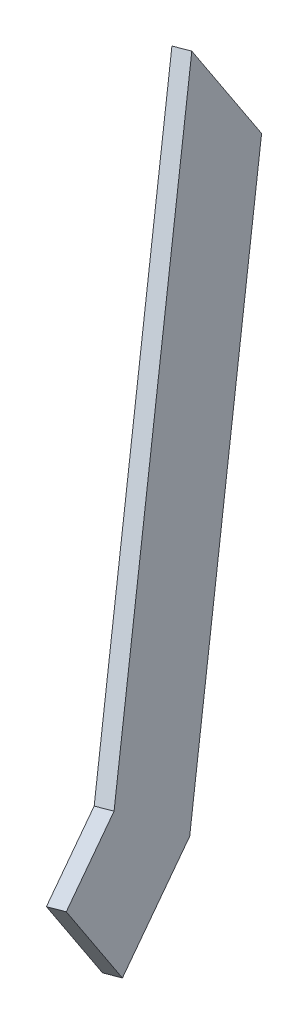
from build123d import *

# Parameters (mm, degrees)
BOSS_EXTRUDE1_DEPTH = 5


with BuildPart() as part:
    # Sketch1 → Boss-Extrude1 (new body)
    with BuildSketch(Plane(origin=(-10.241156446, -1.348234303, 2.051316814), x_dir=(-0.233089191, 0.534113538, -0.812645161), z_dir=(-0.972455361, -0.128022424, 0.19478406))):
        Polygon((-309.360454317, 268.475733816), (-440.665042921, 365.475733816), (-464.859176899, 365.475733816), (-464.859176899, 395.475733816), (-430.785651085, 395.475733816), (-309.360454317, 305.774039369), align=None)
    extrude(amount=-BOSS_EXTRUDE1_DEPTH)


solid = part.part
